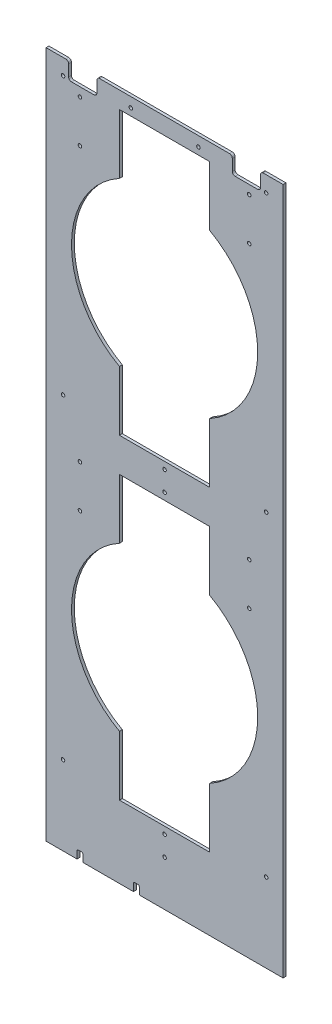
from build123d import *

# Parameters (mm, degrees)
SKETCH1_W                      = 533.4
SKETCH1_H                      = 2413
BOSS_EXTRUDE1_DEPTH            = 6.35
F_5_16_0_3125_DIAMETER_HOLE1_D = 7.9375
SKETCH6_W                      = 533.4
SKETCH6_H                      = 866.14
CUT_EXTRUDE1_DEPTH             = 7.35
SKETCH8_W                      = 63.5
SKETCH8_H                      = 38.1
CUT_EXTRUDE2_DEPTH             = 7.35
FILLET1_R                      = 6.35
F_5_16_0_3125_DIAMETER_HOLE2_D = 7.9375
SKETCH12_W                     = 13.208
SKETCH12_H                     = 19.05
CUT_EXTRUDE3_DEPTH             = 7.35
FILLET2_R                      = 3.175


with BuildPart() as part:
    # Sketch1 → Boss-Extrude1 (new body)
    with BuildSketch(Plane.XY):
        with Locations((0, 1206.5)):
            Rectangle(SKETCH1_W, SKETCH1_H)
        with BuildLine():
            Line((-101.6, 797.56), (101.6, 797.56))
            Line((101.6, 797.56), (101.6, 663.332045059))
            ThreePointArc((101.6, 663.332045059), (209.55, 480.06), (101.6, 296.787954941))
            Line((101.6, 296.787954941), (101.6, 162.56))
            Line((101.6, 162.56), (-101.6, 162.56))
            Line((-101.6, 162.56), (-101.6, 296.787954941))
            ThreePointArc((-101.6, 296.787954941), (-209.55, 480.06), (-101.6, 663.332045059))
            Line((-101.6, 663.332045059), (-101.6, 797.56))
        make_face(mode=Mode.SUBTRACT)
        with BuildLine():
            Line((-101.6, 1508.76), (-101.6, 1374.532045059))
            ThreePointArc((-101.6, 1374.532045059), (-209.55, 1191.26), (-101.6, 1007.987954941))
            Line((-101.6, 1007.987954941), (-101.6, 873.76))
            Line((-101.6, 873.76), (101.6, 873.76))
            Line((101.6, 873.76), (101.6, 1007.987954941))
            ThreePointArc((101.6, 1007.987954941), (209.55, 1191.26), (101.6, 1374.532045059))
            Line((101.6, 1374.532045059), (101.6, 1508.76))
            Line((101.6, 1508.76), (-101.6, 1508.76))
        make_face(mode=Mode.SUBTRACT)
        with BuildLine():
            Line((-101.6, 2219.96), (-101.6, 2085.732045059))
            ThreePointArc((-101.6, 2085.732045059), (-209.55, 1902.46), (-101.6, 1719.187954941))
            Line((-101.6, 1719.187954941), (-101.6, 1584.96))
            Line((-101.6, 1584.96), (101.6, 1584.96))
            Line((101.6, 1584.96), (101.6, 1719.187954941))
            ThreePointArc((101.6, 1719.187954941), (209.55, 1902.46), (101.6, 2085.732045059))
            Line((101.6, 2085.732045059), (101.6, 2219.96))
            Line((101.6, 2219.96), (-101.6, 2219.96))
        make_face(mode=Mode.SUBTRACT)
    extrude(amount=BOSS_EXTRUDE1_DEPTH)

    # 5/16 (0.3125) Diameter Hole1 (through all)
    with Locations(Plane.XY.offset(6.35)):
        with Locations((0, 146.685), (0, 102.235), (-228.6, 177.8), (0, 857.885), (0, 813.435), (228.6, 177.8), (-228.6, 889), (228.6, 889), (-76.2, 1524.635), (-76.2, 1569.085), (76.2, 1569.085), (76.2, 1524.635), (-228.6, 1511.3), (228.6, 1511.3)):
            Hole(F_5_16_0_3125_DIAMETER_HOLE1_D / 2)

    # Sketch6 → Cut-Extrude1 (cut, through all)
    with BuildSketch(Plane.XY.offset(6.35)):
        with Locations((0, 1979.93)):
            Rectangle(SKETCH6_W, SKETCH6_H)
    extrude(amount=-CUT_EXTRUDE1_DEPTH, mode=Mode.SUBTRACT)

    # Sketch8 → Cut-Extrude2 (cut, through all)
    with BuildSketch(Plane.XY.offset(6.35)):
        with Locations((-184.15, 1527.81)):
            Rectangle(SKETCH8_W, SKETCH8_H)
        with Locations((184.15, 1527.81)):
            Rectangle(SKETCH8_W, SKETCH8_H)
    extrude(amount=-CUT_EXTRUDE2_DEPTH, mode=Mode.SUBTRACT)

    # Fillet1
    fillet1_edges = [part.edges().sort_by_distance(p)[0] for p in [
        (-152.4, 1508.76, 3.175),
        (-215.9, 1508.76, 3.175),
        (-215.9, 1546.86, 3.175),
        (-152.4, 1546.86, 3.175),
        (152.4, 1508.76, 3.175),
        (152.4, 1546.86, 3.175),
        (215.9, 1546.86, 3.175),
        (215.9, 1508.76, 3.175),
    ]]
    fillet(fillet1_edges, radius=FILLET1_R)

    # 5/16 (0.3125) Diameter Hole2 (through all)
    with Locations(Plane.XY.offset(6.35)):
        with Locations((-190.5, 682.382045059), (-190.5, 777.632045059), (190.5, 777.632045059), (190.5, 682.382045059), (-190.5, 1393.582045059), (-190.5, 1488.832045059), (190.5, 1488.832045059), (190.5, 1393.582045059)):
            Hole(F_5_16_0_3125_DIAMETER_HOLE2_D / 2)

    # Sketch12 → Cut-Extrude3 (cut, through all)
    with BuildSketch(Plane.XY.offset(6.35)):
        with Locations((-63.5, 9.525)):
            Rectangle(SKETCH12_W, SKETCH12_H)
        with Locations((-190.5, 9.525)):
            Rectangle(SKETCH12_W, SKETCH12_H)
    extrude(amount=-CUT_EXTRUDE3_DEPTH, mode=Mode.SUBTRACT)

    # Fillet2
    fillet2_edges = [part.edges().sort_by_distance(p)[0] for p in [
        (-56.896, 19.05, 3.175),
        (-70.104, 19.05, 3.175),
        (-183.896, 19.05, 3.175),
        (-197.104, 19.05, 3.175),
    ]]
    fillet(fillet2_edges, radius=FILLET2_R)


solid = part.part
